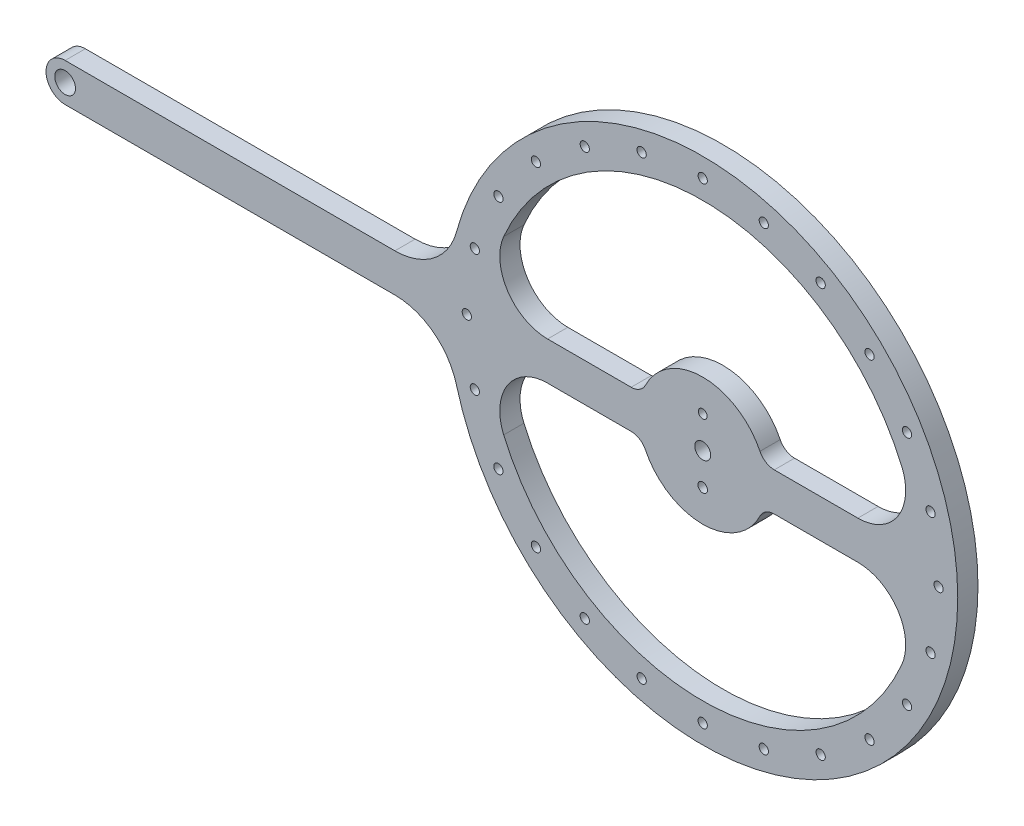
from build123d import *

# Parameters (mm, degrees)
SKETCH1_R           = 1.450000001
SKETCH1_R_2         = 3.250000001
SKETCH1_R_3         = 1.5
SKETCH1_R_4         = 2.5
SKETCH1_R_5         = 1.375000001
BOSS_EXTRUDE2_DEPTH = 6.35


with BuildPart() as part:
    # Sketch1 → Boss-Extrude2 (new body)
    with BuildSketch(Plane.XY):
        with BuildLine():
            Line((-155.352886895, 10.211716756), (-51.913748531, 10.211716756))
            ThreePointArc((-51.913748531, 10.211716756), (-39.74822347, 6.086224622), (-32.601576204, -4.588283244))
            ThreePointArc((-32.601576204, -4.588283244), (53.610301025, -63.284580406), (124.587919611, 13.13479368))
            ThreePointArc((124.587919611, 13.13479368), (56.661218885, 95.304455124), (-32.601576204, 37.011716756))
            ThreePointArc((-32.601576204, 37.011716756), (-39.74822347, 26.33720889), (-51.913748531, 22.211716756))
            Line((-51.913748531, 22.211716756), (-155.352886895, 22.211716756))
            ThreePointArc((-155.352886895, 22.211716756), (-161.352886895, 16.211716756), (-155.352886895, 10.211716756))
        make_face()
        with Locations((-19.438766774, -20.788283242)):
            Circle(SKETCH1_R, mode=Mode.SUBTRACT)
        with Locations((-26.831398039, -2.940892579)):
            Circle(SKETCH1_R, mode=Mode.SUBTRACT)
        with Locations((-155.352886895, 16.211716756)):
            Circle(SKETCH1_R_2, mode=Mode.SUBTRACT)
        with Locations((-26.831398039, 35.364326096)):
            Circle(SKETCH1_R, mode=Mode.SUBTRACT)
        with Locations((-19.438766774, 53.211716759)):
            Circle(SKETCH1_R, mode=Mode.SUBTRACT)
        with Locations((-29.352886893, 16.211716758)):
            Circle(SKETCH1_R, mode=Mode.SUBTRACT)
        with Locations((44.647113106, 6.211716759)):
            Circle(SKETCH1_R_3, mode=Mode.SUBTRACT)
        with Locations((116.125624253, -2.940892579)):
            Circle(SKETCH1_R, mode=Mode.SUBTRACT)
        with Locations((108.732992988, -20.788283242)):
            Circle(SKETCH1_R, mode=Mode.SUBTRACT)
        with Locations((96.973014915, -36.114185049)):
            Circle(SKETCH1_R, mode=Mode.SUBTRACT)
        with Locations((81.647113106, -47.874163121)):
            Circle(SKETCH1_R, mode=Mode.SUBTRACT)
        with Locations((63.799722443, -55.266794386)):
            Circle(SKETCH1_R, mode=Mode.SUBTRACT)
        with Locations((44.647113106, -57.788283242)):
            Circle(SKETCH1_R, mode=Mode.SUBTRACT)
        with Locations((25.494503768, -55.266794386)):
            Circle(SKETCH1_R, mode=Mode.SUBTRACT)
        with Locations((7.647113108, -47.874163121)):
            Circle(SKETCH1_R, mode=Mode.SUBTRACT)
        with Locations((-7.678788702, -36.114185049)):
            Circle(SKETCH1_R, mode=Mode.SUBTRACT)
        with Locations((44.647113106, 16.211716756)):
            Circle(SKETCH1_R_4, mode=Mode.SUBTRACT)
        with Locations((-7.678788702, 68.537618566)):
            Circle(SKETCH1_R, mode=Mode.SUBTRACT)
        with Locations((7.647113108, 80.297596638)):
            Circle(SKETCH1_R, mode=Mode.SUBTRACT)
        with Locations((25.494503768, 87.690227903)):
            Circle(SKETCH1_R, mode=Mode.SUBTRACT)
        with Locations((44.647113106, 90.211716759)):
            Circle(SKETCH1_R, mode=Mode.SUBTRACT)
        with Locations((63.799722443, 87.690227903)):
            Circle(SKETCH1_R, mode=Mode.SUBTRACT)
        with Locations((81.647113106, 80.297596638)):
            Circle(SKETCH1_R, mode=Mode.SUBTRACT)
        with Locations((96.973014915, 68.537618566)):
            Circle(SKETCH1_R, mode=Mode.SUBTRACT)
        with Locations((108.732992988, 53.211716759)):
            Circle(SKETCH1_R, mode=Mode.SUBTRACT)
        with Locations((116.125624253, 35.364326096)):
            Circle(SKETCH1_R, mode=Mode.SUBTRACT)
        with Locations((44.647113106, 26.211716758)):
            Circle(SKETCH1_R_5, mode=Mode.SUBTRACT)
        with Locations((118.647113104, 16.211716758)):
            Circle(SKETCH1_R, mode=Mode.SUBTRACT)
        with BuildLine():
            Line((-4.014987137, 10.211716754), (22.197168785, 10.211716754))
            ThreePointArc((22.197168785, 10.211716754), (24.842920096, 9.454357441), (26.687157649, 7.411716754))
            ThreePointArc((26.687157649, 7.411716754), (44.647113107, -3.788283245), (62.607068564, 7.411716755))
            ThreePointArc((62.607068564, 7.411716755), (64.451306117, 9.454357442), (67.097057428, 10.211716755))
            Line((67.097057428, 10.211716755), (93.309213348, 10.211716755))
            ThreePointArc((93.309213348, 10.211716755), (105.842188723, 3.453350593), (107.081505871, -10.731679472))
            ThreePointArc((107.081505871, -10.731679472), (44.647113106, -51.788283245), (-17.787279658, -10.731679472))
            ThreePointArc((-17.787279658, -10.731679472), (-16.54796251, 3.453350591), (-4.014987137, 10.211716754))
        make_face(mode=Mode.SUBTRACT)
        with BuildLine():
            Line((93.309213348, 22.211716754), (67.097057429, 22.211716754))
            ThreePointArc((67.097057429, 22.211716754), (64.451306116, 22.969076068), (62.607068563, 25.011716756))
            ThreePointArc((62.607068563, 25.011716756), (44.647113106, 36.211716756), (26.68715765, 25.011716756))
            ThreePointArc((26.68715765, 25.011716756), (24.842920097, 22.969076069), (22.197168786, 22.211716756))
            Line((22.197168786, 22.211716756), (-4.014987136, 22.211716756))
            ThreePointArc((-4.014987136, 22.211716756), (-16.547962509, 28.970082919), (-17.787279657, 43.155112983))
            ThreePointArc((-17.787279657, 43.155112983), (44.647113107, 84.211716756), (107.08150587, 43.155112983))
            ThreePointArc((107.08150587, 43.155112983), (105.842188723, 28.970082917), (93.309213348, 22.211716754))
        make_face(mode=Mode.SUBTRACT)
    extrude(amount=BOSS_EXTRUDE2_DEPTH)


solid = part.part
